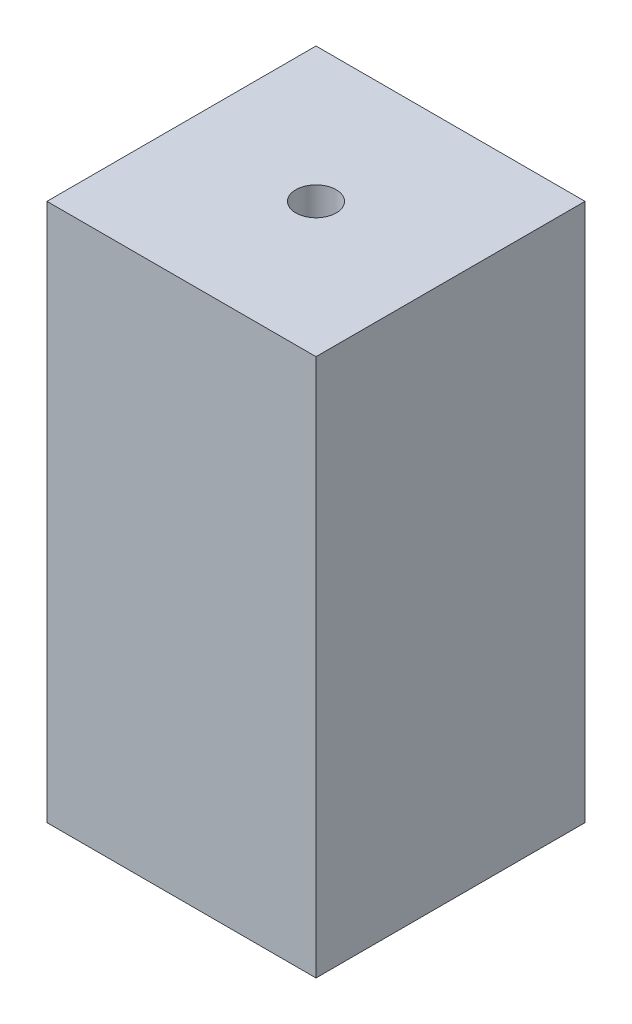
from build123d import *

# Parameters (mm, degrees)
SKETCH1_W           = 10
SKETCH1_H           = 10
BOSS_EXTRUDE1_DEPTH = 20
SKETCH2_R           = 0.75
CUT_EXTRUDE2_DEPTH  = 21


with BuildPart() as part:
    # Sketch1 → Boss-Extrude1 (new body)
    with BuildSketch(Plane(origin=(0, 0, 0), x_dir=(1, 0, 0), z_dir=(0, 1, 0))):
        with Locations((5, 5)):
            Rectangle(SKETCH1_W, SKETCH1_H)
    extrude(amount=BOSS_EXTRUDE1_DEPTH)

    # Sketch2 → Cut-Extrude2 (cut)
    with BuildSketch(Plane(origin=(0, 20, 0), x_dir=(1, 0, 0), z_dir=(0, 1, 0))):
        with Locations((5, 5)):
            Circle(SKETCH2_R)
    extrude(amount=-CUT_EXTRUDE2_DEPTH, mode=Mode.SUBTRACT)


solid = part.part
